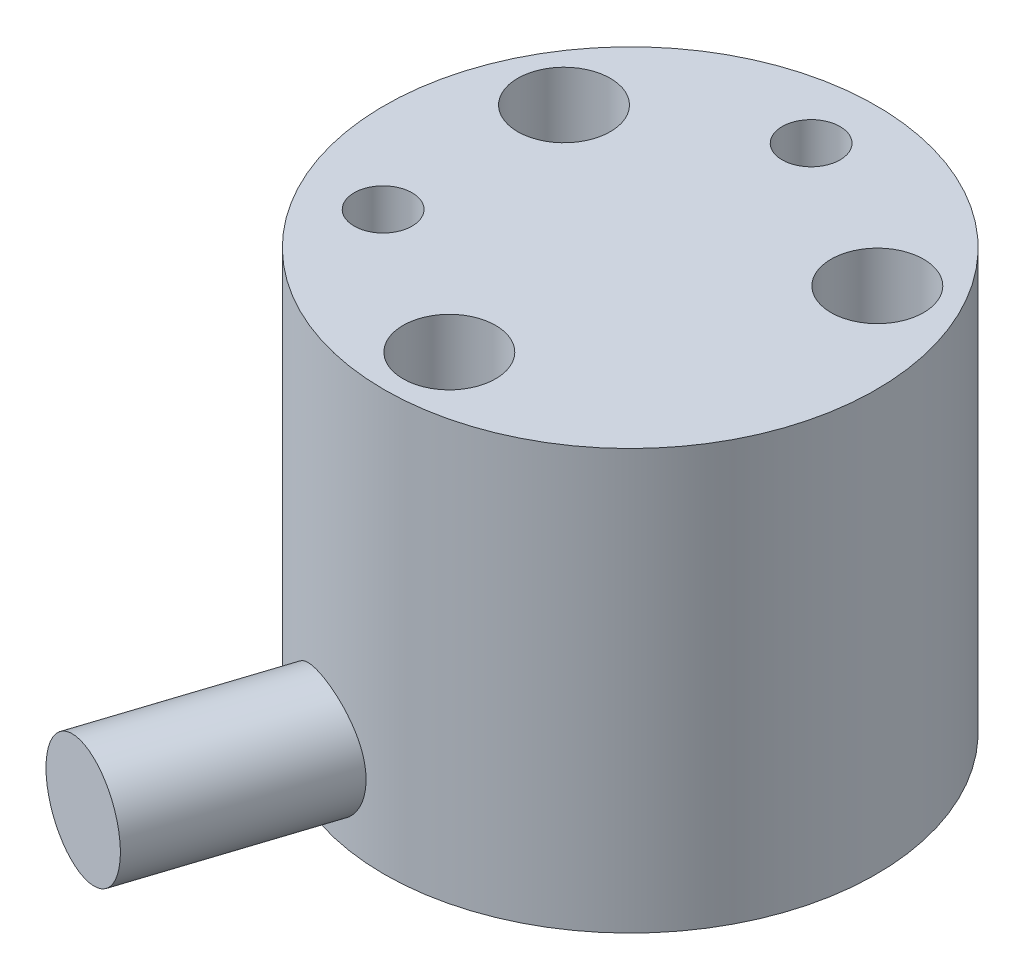
from build123d import *

# Parameters (mm, degrees)
SKETCH1_W                    = 8.5
SKETCH1_H                    = 14.5
CUT_EXTRUDE1_REACH           = 2.1
CUT_EXTRUDE2_REACH           = 2.1
CUT_EXTRUDE3_REACH           = 2.1
CUT_EXTRUDE4_REACH           = 2.1
F_2_0_2_DIAMETER_HOLE1_D     = 2
F_2_0_2_DIAMETER_HOLE1_DEPTH = 3
F_2_0_2_DIAMETER_HOLE2_D     = 3.2
F_2_0_2_DIAMETER_HOLE2_DEPTH = 3.5
F_2_0_2_DIAMETER_HOLE3_D     = 2
F_2_0_2_DIAMETER_HOLE3_DEPTH = 3
F_2_0_2_DIAMETER_HOLE4_D     = 3.2
F_2_0_2_DIAMETER_HOLE4_DEPTH = 3.5


with BuildPart() as part:
    # Sketch1 → Revolve1 (revolve)
    with BuildSketch(Plane(origin=(0, 0, 0), x_dir=(-1, 0, 0), z_dir=(0, 0, -1))):
        with Locations((-4.25, 7.25)):
            Rectangle(SKETCH1_W, SKETCH1_H)
    revolve(axis=Axis((0, 0, 0), (0, 1, 0)))

    # Sketch2 → Cut-Extrude1 (cut, up to next)
    with BuildSketch(Plane(origin=(-8.4, 0, 0), x_dir=(0, 0, -1), z_dir=(1, 0, 0)), mode=Mode.PRIVATE) as cut_extrude1_sk1:
        Polygon((0.9, 13.234042555), (0.9, 13.297872335), (0.649999993, 13.297872335), (0.649999993, 13.553191453), (0.587500007, 13.553191453), (0.587500007, 13.297872335), (0.3375, 13.297872335), (0.3375, 13.234042555), (0.587500007, 13.234042555), (0.587500007, 12.978723392), (0.649999993, 12.978723392), (0.649999993, 13.234042555), align=None)
    cut_extrude1_tool1 = extrude(cut_extrude1_sk1.sketch, amount=-CUT_EXTRUDE1_REACH, mode=Mode.PRIVATE) & part.part
    add(cut_extrude1_tool1.solids().sort_by_distance((-8.4, 13.265957, -0.61875))[0], mode=Mode.SUBTRACT)

    # Sketch3 → Cut-Extrude2 (cut, up to next)
    with BuildSketch(Plane.XY.offset(-8.4), mode=Mode.PRIVATE) as cut_extrude2_sk1:
        Polygon((1, 13.234042555), (1, 13.297872335), (0.749999993, 13.297872335), (0.749999993, 13.553191453), (0.687500007, 13.553191453), (0.687500007, 13.297872335), (0.4375, 13.297872335), (0.4375, 13.234042555), (0.687500007, 13.234042555), (0.687500007, 12.978723392), (0.749999993, 12.978723392), (0.749999993, 13.234042555), align=None)
    cut_extrude2_tool1 = extrude(cut_extrude2_sk1.sketch, amount=-CUT_EXTRUDE2_REACH, mode=Mode.PRIVATE) & part.part
    add(cut_extrude2_tool1.solids().sort_by_distance((0.71875, 13.265957, -8.4))[0], mode=Mode.SUBTRACT)

    # Sketch4 → Cut-Extrude3 (cut, up to next)
    with BuildSketch(Plane.XY.offset(-8.4), mode=Mode.PRIVATE) as cut_extrude3_sk1:
        Polygon((-0.875, 12.5), (-0.43749997, 13.106382996), (-3e-08, 12.5), (0.18749997, 12.5), (-0.34374997, 13.265957445), (0.18749997, 14), (-3e-08, 14), (-0.43749997, 13.393617004), (-0.875, 14), (-1.0625, 14), (-0.53125006, 13.265957445), (-1.0625, 12.5), align=None)
    cut_extrude3_tool1 = extrude(cut_extrude3_sk1.sketch, amount=-CUT_EXTRUDE3_REACH, mode=Mode.PRIVATE) & part.part
    add(cut_extrude3_tool1.solids().sort_by_distance((-0.4375, 13.242259, -8.4))[0], mode=Mode.SUBTRACT)

    # Sketch5 → Cut-Extrude4 (cut, up to next)
    with BuildSketch(Plane(origin=(-8.4, 0, 0), x_dir=(0, 0, -1), z_dir=(1, 0, 0)), mode=Mode.PRIVATE) as cut_extrude4_sk1:
        Polygon((-1.10000006, 14), (-0.6, 13.265957445), (-0.6, 12.5), (-0.4125, 12.5), (-0.4125, 13.265957445), (0.08749997, 14), (-0.10000003, 14), (-0.50625, 13.393617004), (-0.91250006, 14), align=None)
    cut_extrude4_tool1 = extrude(cut_extrude4_sk1.sketch, amount=-CUT_EXTRUDE4_REACH, mode=Mode.PRIVATE) & part.part
    add(cut_extrude4_tool1.solids().sort_by_distance((-8.4, 13.37564, 0.50625))[0], mode=Mode.SUBTRACT)

    # Sketch6 → Revolve2 (revolve)
    with BuildSketch(Plane(origin=(0, 2.49, 0), x_dir=(1, 0, 0), z_dir=(0, 1, 0))):
        Polygon((-6.537367948, -13.647813756), (-4.635254916, -14.265847744), (-2.552899345, -7.857016287), (-4.455012378, -7.238982298), align=None)
    revolve(axis=Axis((-4.635254916, 2.49, 14.265847744), (0.309016994, 0, -0.951056516)))

    # Ø2.0 (2) Diameter Hole1
    with Locations(Plane(origin=(0, 0, 0), x_dir=(-1, 0, 0), z_dir=(0, -1, 0))):
        with Locations((1.08530111, 6.155048456), (-5.87307888, -2.137625896)):
            Hole(F_2_0_2_DIAMETER_HOLE1_D / 2, depth=F_2_0_2_DIAMETER_HOLE1_DEPTH)

    # Ø2.0 (2) Diameter Hole2
    with Locations(Plane(origin=(0, 0, 0), x_dir=(-1, 0, 0), z_dir=(0, -1, 0))):
        with Locations((6.226216863, -0.544723392), (-3.584852727, -5.119700277), (-2.641364136, 5.664423669)):
            Hole(F_2_0_2_DIAMETER_HOLE2_D / 2, depth=F_2_0_2_DIAMETER_HOLE2_DEPTH)

    # Ø2.0 (2) Diameter Hole3
    with Locations(Plane(origin=(0, 14.5, 0), x_dir=(1, 0, 0), z_dir=(0, 1, 0))):
        with Locations((0, 6.25), (-5.412658774, -3.125)):
            Hole(F_2_0_2_DIAMETER_HOLE3_D / 2, depth=F_2_0_2_DIAMETER_HOLE3_DEPTH)

    # Ø2.0 (2) Diameter Hole4
    with Locations(Plane(origin=(0, 14.5, 0), x_dir=(1, 0, 0), z_dir=(0, 1, 0))):
        with Locations((0, -6.25), (5.412658774, 3.125), (-5.412658774, 3.125)):
            Hole(F_2_0_2_DIAMETER_HOLE4_D / 2, depth=F_2_0_2_DIAMETER_HOLE4_DEPTH)


solid = part.part
